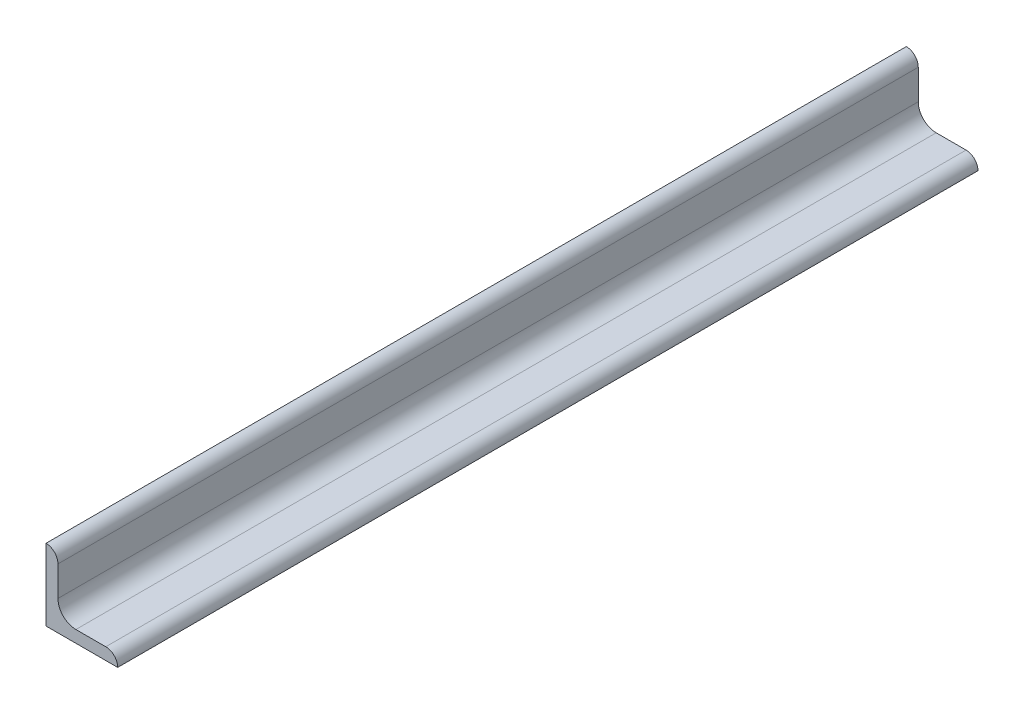
from build123d import *

# Parameters (mm, degrees)
BASESTEELANGLE_DEPTH = 114.3


with BuildPart() as part:
    # Sketch1 → BaseSteelAngle (new body, symmetric)
    with BuildSketch(Plane.XY):
        with BuildLine():
            Line((0, 0), (0, 19.05))
            Line((0, 19.05), (0.00508, 19.05))
            ThreePointArc((0.00508, 19.05), (2.246551928, 18.121551928), (3.175, 15.88008))
            Line((3.175, 15.88008), (3.175, 7.9375))
            ThreePointArc((3.175, 7.9375), (4.569903955, 4.569903955), (7.9375, 3.175))
            Line((7.9375, 3.175), (15.88008, 3.175))
            ThreePointArc((15.88008, 3.175), (18.121551928, 2.246551928), (19.05, 0.00508))
            Line((19.05, 0.00508), (19.05, 0))
            Line((19.05, 0), (0, 0))
        make_face()
    extrude(amount=BASESTEELANGLE_DEPTH, both=True)


solid = part.part
